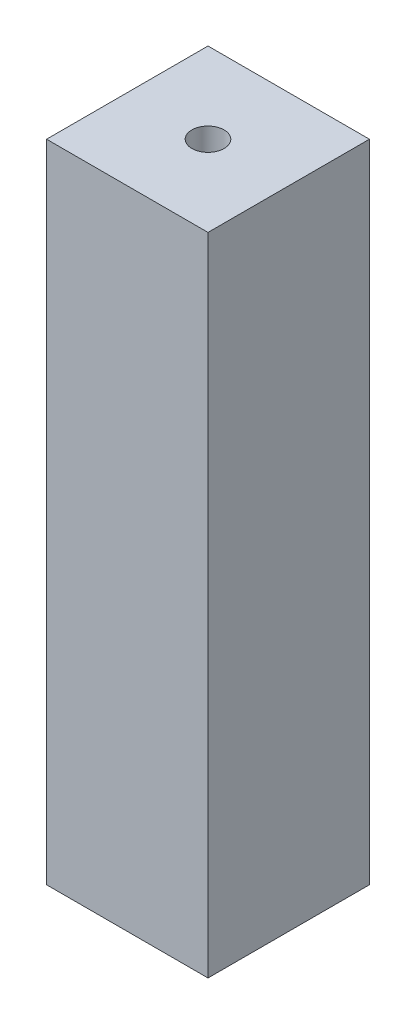
from build123d import *

# Parameters (mm, degrees)
SKETCH1_W           = 15
SKETCH1_H           = 15
SKETCH1_R           = 1.5
BOSS_EXTRUDE1_DEPTH = 60


with BuildPart() as part:
    # Sketch1 → Boss-Extrude1 (new body)
    with BuildSketch(Plane(origin=(0, 0, 0), x_dir=(1, 0, 0), z_dir=(0, 1, 0))):
        Rectangle(SKETCH1_W, SKETCH1_H)
        Circle(SKETCH1_R, mode=Mode.SUBTRACT)
    extrude(amount=BOSS_EXTRUDE1_DEPTH)


solid = part.part
